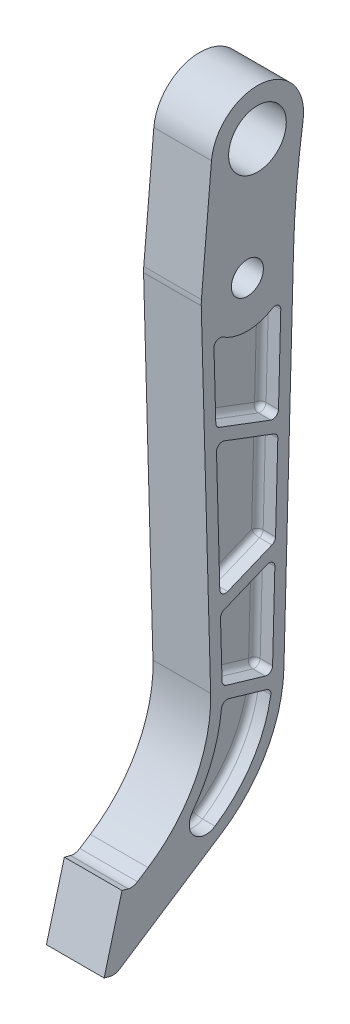
from build123d import *

# Parameters (mm, degrees)
SKETCH1_R            = 8.8003507
SKETCH1_R_2          = 15.875
BOSS_EXTRUDE1_DEPTH  = 15.875
CUT_EXTRUDE1_DEPTH   = 10
FILLET1_R            = 3.175
FILLET1_OF_MIRROR2_R = 3.175


with BuildPart() as part:
    # Sketch1 → Boss-Extrude1 (new body, symmetric)
    with BuildSketch(Plane(origin=(0, 0, 0), x_dir=(0, 0, -1), z_dir=(1, 0, 0))):
        with BuildLine():
            Line((-25.39034411, -0.700304185), (-20.223925011, -188.014847764))
            ThreePointArc((-20.223925011, -188.014847764), (-28.875615942, -225.436838118), (-54.68211929, -253.884711554))
            Line((-54.68211929, -253.884711554), (-60.516881835, -257.701373117))
            ThreePointArc((-60.516881835, -257.701373117), (-62.989212347, -258.657461897), (-65.636452609, -258.520922845))
            Line((-65.636452609, -258.520922845), (-69.027039329, -257.612417871))
            Line((-69.027039329, -257.612417871), (-78.888044947, -294.414191853))
            Line((-78.888044947, -294.414191853), (-75.497458227, -295.322696826))
            ThreePointArc((-75.497458227, -295.322696826), (-72.850217966, -295.459235879), (-70.377887453, -294.503147099))
            Line((-70.377887453, -294.503147099), (-14.336567795, -257.845142759))
            ThreePointArc((-14.336567795, -257.845142759), (10.482969023, -231.222969231), (20.123027121, -196.125692826))
            Line((20.123027121, -196.125692826), (25.4, 0))
            ThreePointArc((25.4, 0), (27.123066226, 29.942448421), (30.673225485, 59.723575732))
            ThreePointArc((30.673225485, 59.723575732), (8.55205829, 88.722625141), (-19.747815198, 65.713755866))
            Line((-19.747815198, 65.713755866), (-25.303345332, 2.213755866))
            ThreePointArc((-25.303345332, 2.213755866), (-25.38868791, 0.757975062), (-25.39034411, -0.700304185))
        make_face()
        Circle(SKETCH1_R, mode=Mode.SUBTRACT)
        with Locations((5.555530134, 63.5)):
            Circle(SKETCH1_R_2, mode=Mode.SUBTRACT)
    extrude(amount=BOSS_EXTRUDE1_DEPTH, both=True)

    # Sketch2 → Cut-Extrude1 (cut)
    with BuildSketch(Plane(origin=(15.875, 0, 0), x_dir=(0, 0, -1), z_dir=(1, 0, 0))):
        with BuildLine():
            Line((-11.660302985, -188.490127485), (9.818309103, -194.793607776))
            ThreePointArc((9.818309103, -194.793607776), (12.580917397, -194.314044839), (13.886242269, -191.832490452))
            Line((13.886242269, -191.832490452), (15.141700078, -145.171736569))
            ThreePointArc((15.141700078, -145.171736569), (13.770751444, -142.472881917), (10.760959128, -142.149668662))
            Line((10.760959128, -142.149668662), (-12.818942026, -151.840344616))
            ThreePointArc((-12.818942026, -151.840344616), (-14.273641559, -153.045956724), (-14.785845463, -154.864554658))
            Line((-14.785845463, -154.864554658), (-13.940014207, -185.531152296))
            ThreePointArc((-13.940014207, -185.531152296), (-13.281332503, -187.381355252), (-11.660302985, -188.490127485))
        make_face()
        with BuildLine():
            Line((15.515269566, -131.287531301), (16.765792896, -84.810173886))
            ThreePointArc((16.765792896, -84.810173886), (16.228003809, -82.955088584), (14.71468148, -81.754916051))
            Line((14.71468148, -81.754916051), (-12.693209932, -71.393513614))
            ThreePointArc((-12.693209932, -71.393513614), (-15.656229887, -71.776100059), (-16.989779352, -74.449581958))
            Line((-16.989779352, -74.449581958), (-15.174226134, -141.292142862))
            ThreePointArc((-15.174226134, -141.292142862), (-13.732014902, -143.867162368), (-10.793507095, -144.142608485))
            Line((-10.793507095, -144.142608485), (13.548307769, -134.138807433))
            ThreePointArc((13.548307769, -134.138807433), (14.954876957, -133.005038153), (15.515269566, -131.287531301))
        make_face()
        with BuildLine():
            Line((-15.331296871, -63.607584159), (12.830833159, -74.254122353))
            ThreePointArc((12.830833159, -74.254122353), (15.723262531, -73.920322691), (17.12742449, -71.369656293))
            Line((17.12742449, -71.369656293), (18.394713184, -24.269191925))
            ThreePointArc((18.394713184, -24.269191925), (16.792875178, -21.425282131), (13.529654942, -21.496707589))
            ThreePointArc((13.529654942, -21.496707589), (0.003660623, -25.399999736), (-13.523458211, -21.500606457))
            ThreePointArc((-13.523458211, -21.500606457), (-16.787232142, -21.430425741), (-18.387683501, -24.275720287))
            Line((-18.387683501, -24.275720287), (-17.382349928, -60.725260234))
            ThreePointArc((-17.382349928, -60.725260234), (-16.7954463, -62.478544936), (-15.331296871, -63.607584159))
        make_face()
        with BuildLine():
            Line((-10.195205463, -195.537911468), (10.666732473, -201.660412031))
            ThreePointArc((10.666732473, -201.660412031), (12.458283079, -203.013407124), (12.907034325, -205.213150658))
            ThreePointArc((12.907034325, -205.213150658), (2.53678877, -232.111442282), (-17.812637633, -252.531063489))
            ThreePointArc((-17.812637633, -252.531063489), (-29.49364525, -251.143961365), (-30.171678071, -239.400441332))
            ThreePointArc((-30.171678071, -239.400441332), (-19.412569014, -219.918686135), (-14.248756518, -198.270770444))
            ThreePointArc((-14.248756518, -198.270770444), (-12.864146304, -195.95184033), (-10.195205463, -195.537911468))
        make_face()
    cut_extrude1 = extrude(amount=-CUT_EXTRUDE1_DEPTH, mode=Mode.SUBTRACT)

    # Fillet1
    fillet1_edges = [part.edges().sort_by_distance(p)[0] for p in [
        (5.875, -219.918686135, 19.412569014),
        (5.875, -195.95184033, 12.864146304),
        (5.875, -198.59916175, -0.235763505),
        (5.875, -203.013407124, -12.458283079),
        (5.875, -232.111442282, -2.53678877),
        (5.875, -251.143961365, 29.49364525),
        (5.875, -194.314044839, -12.580917397),
        (5.875, -191.64186763, 0.920996941),
        (5.875, -187.381355252, 13.281332503),
        (5.875, -170.197853477, 14.362929835),
        (5.875, -153.045956724, 14.273641559),
        (5.875, -146.995006639, 1.028991449),
        (5.875, -142.472881917, -13.770751444),
        (5.875, -168.50211351, -14.513971173),
        (5.875, -133.005038153, -14.954876957),
        (5.875, -139.140707959, -1.377400337),
        (5.875, -143.867162368, 13.732014902),
        (5.875, -107.87086241, 16.082002743),
        (5.875, -71.776100059, 15.656229887),
        (5.875, -76.574214832, -1.010735774),
        (5.875, -82.955088584, -16.228003809),
        (5.875, -108.048852594, -16.140531231),
        (5.875, -21.425282131, -16.792875178),
        (5.875, -47.819424109, -17.761068837),
        (5.875, -73.920322691, -15.723262531),
        (5.875, -68.930853256, 1.250231856),
        (5.875, -62.478544936, 16.7954463),
        (5.875, -42.500490261, 17.885016715),
        (5.875, -21.430425741, 16.787232142),
        (5.875, -25.399999736, -0.003660623),
    ]]
    fillet(fillet1_edges, radius=FILLET1_R)

    # Mirror2: Cut-Extrude1 across plane
    add(cut_extrude1.mirror(Plane(origin=(0, 0, 0), x_dir=(0, 0, 1), z_dir=(1, 0, 0))), mode=Mode.SUBTRACT)

    # Fillet1 of Mirror2
    fillet1_of_mirror2_edges = [part.edges().sort_by_distance(p)[0] for p in [
        (-5.875, -219.918686135, 19.412569014),
        (-5.875, -195.95184033, 12.864146304),
        (-5.875, -198.59916175, -0.235763505),
        (-5.875, -203.013407124, -12.458283079),
        (-5.875, -232.111442282, -2.53678877),
        (-5.875, -251.143961365, 29.49364525),
        (-5.875, -194.314044839, -12.580917397),
        (-5.875, -191.64186763, 0.920996941),
        (-5.875, -187.381355252, 13.281332503),
        (-5.875, -170.197853477, 14.362929835),
        (-5.875, -153.045956724, 14.273641559),
        (-5.875, -146.995006639, 1.028991449),
        (-5.875, -142.472881917, -13.770751444),
        (-5.875, -168.50211351, -14.513971173),
        (-5.875, -133.005038153, -14.954876957),
        (-5.875, -139.140707959, -1.377400337),
        (-5.875, -143.867162368, 13.732014902),
        (-5.875, -107.87086241, 16.082002743),
        (-5.875, -71.776100059, 15.656229887),
        (-5.875, -76.574214832, -1.010735774),
        (-5.875, -82.955088584, -16.228003809),
        (-5.875, -108.048852594, -16.140531231),
        (-5.875, -21.425282131, -16.792875178),
        (-5.875, -47.819424109, -17.761068837),
        (-5.875, -73.920322691, -15.723262531),
        (-5.875, -68.930853256, 1.250231856),
        (-5.875, -62.478544936, 16.7954463),
        (-5.875, -42.500490261, 17.885016715),
        (-5.875, -21.430425741, 16.787232142),
        (-5.875, -25.399999736, -0.003660623),
    ]]
    fillet(fillet1_of_mirror2_edges, radius=FILLET1_OF_MIRROR2_R)


solid = part.part
